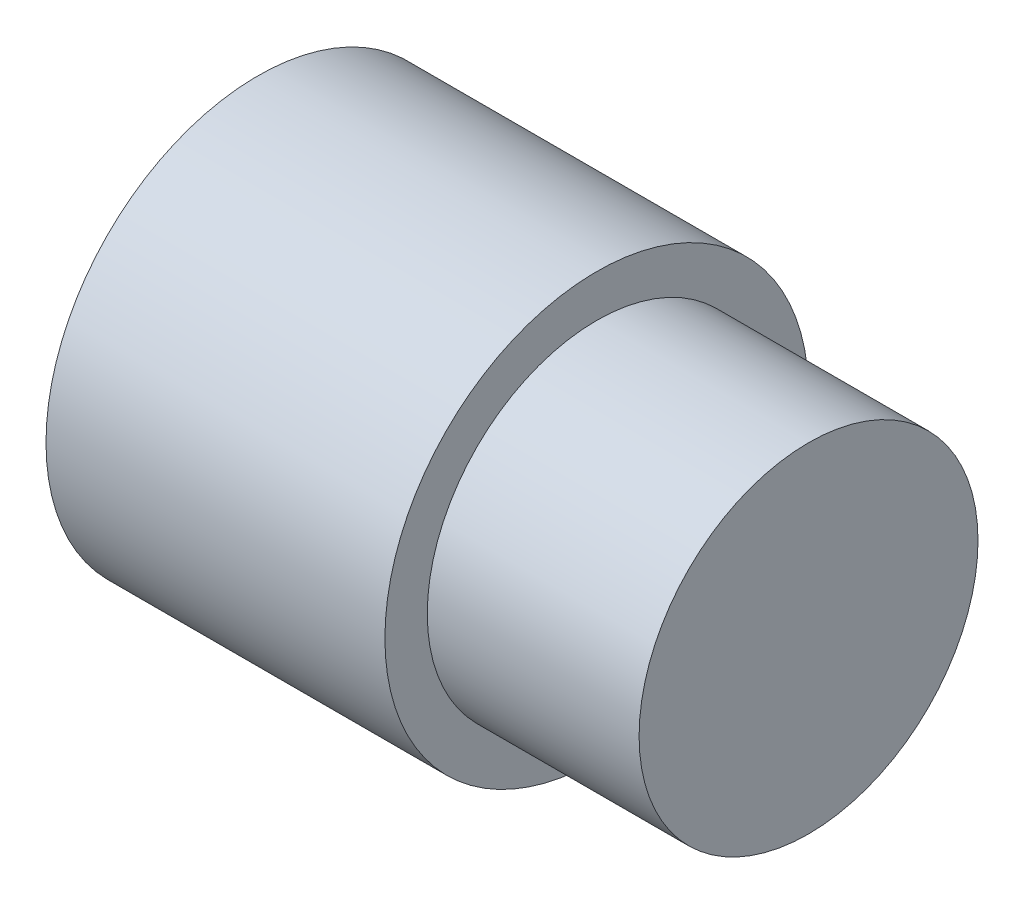
from build123d import *


with BuildPart() as part:
    # Sketch1 → Revolve1 (revolve)
    with BuildSketch(Plane(origin=(0, 0, 0), x_dir=(1, 0, 0), z_dir=(0, 1, 0))):
        Polygon((25, 0), (25, 20), (0, 20), (0, 25), (-40, 25), (-40, 0), align=None)
    revolve(axis=Axis((-47.747747748, 0, 0), (1, 0, 0)))


solid = part.part
